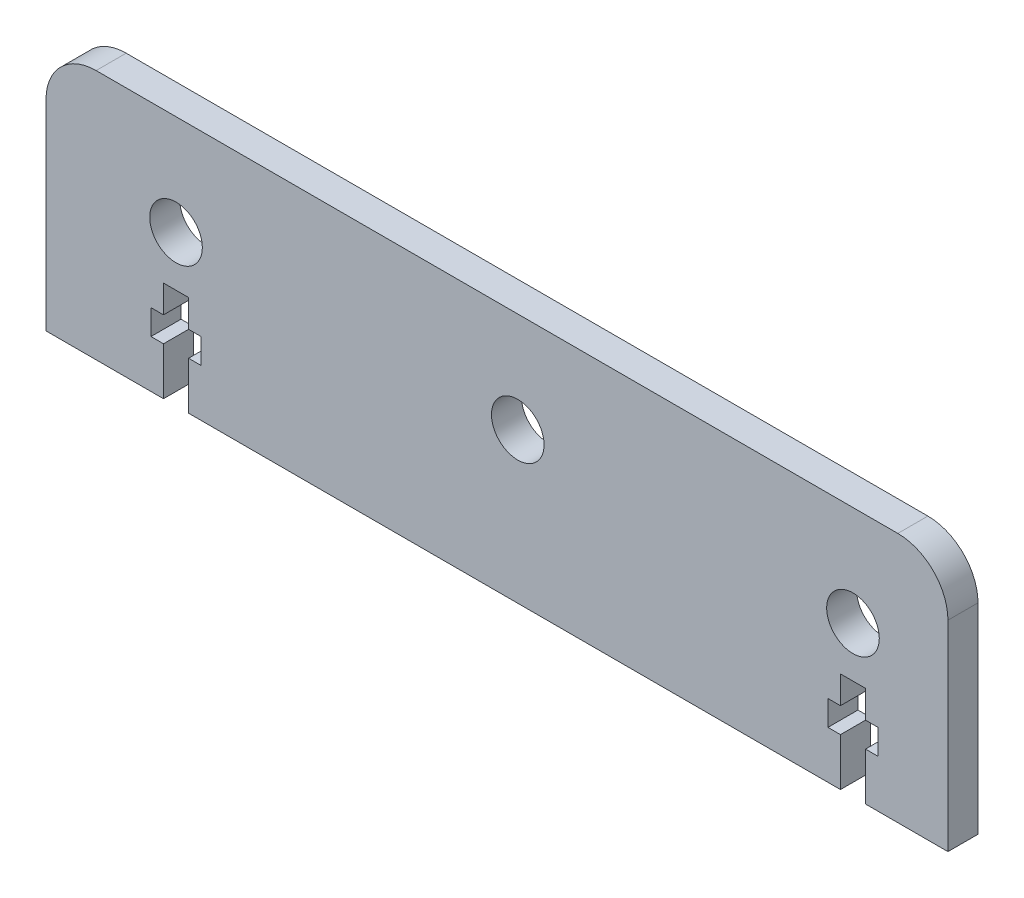
from build123d import *

# Parameters (mm, degrees)
SKETCH1_W           = 180
SKETCH1_H           = 50
BOSS_EXTRUDE1_DEPTH = 6
SKETCH2_R           = 5.25
CUT_EXTRUDE1_DEPTH  = 7
FILLET1_R           = 10
SKETCH3_W           = 5
SKETCH3_H           = 20
SKETCH3_W_2         = 10
SKETCH3_H_2         = 5
CUT_EXTRUDE2_DEPTH  = 7


with BuildPart() as part:
    # Sketch1 → Boss-Extrude1 (new body)
    with BuildSketch(Plane.XY):
        Rectangle(SKETCH1_W, SKETCH1_H)
    extrude(amount=BOSS_EXTRUDE1_DEPTH)

    # Sketch2 → Cut-Extrude1 (cut, through all)
    with BuildSketch(Plane.XY.offset(6)):
        with Locations((-64.05, 5)):
            Circle(SKETCH2_R)
        with Locations((4.15, 5)):
            Circle(SKETCH2_R)
        with Locations((71.05, 5)):
            Circle(SKETCH2_R)
    extrude(amount=-CUT_EXTRUDE1_DEPTH, mode=Mode.SUBTRACT)

    # Fillet1
    fillet1_edges = [part.edges().sort_by_distance(p)[0] for p in [
        (-90, 25, 3),
        (90, 25, 3),
    ]]
    fillet(fillet1_edges, radius=FILLET1_R)

    # Sketch3 → Cut-Extrude2 (cut, through all)
    with BuildSketch(Plane(origin=(0, 0, 0), x_dir=(-1, 0, 0), z_dir=(0, 0, -1))):
        with Locations((-71.05, -15)):
            Rectangle(SKETCH3_W, SKETCH3_H)
        with Locations((64.05, -15)):
            Rectangle(SKETCH3_W, SKETCH3_H)
        with Locations((-71.05, -13)):
            Rectangle(SKETCH3_W_2, SKETCH3_H_2)
        with Locations((64.05, -13)):
            Rectangle(SKETCH3_W_2, SKETCH3_H_2)
    extrude(amount=-CUT_EXTRUDE2_DEPTH, mode=Mode.SUBTRACT)


solid = part.part
